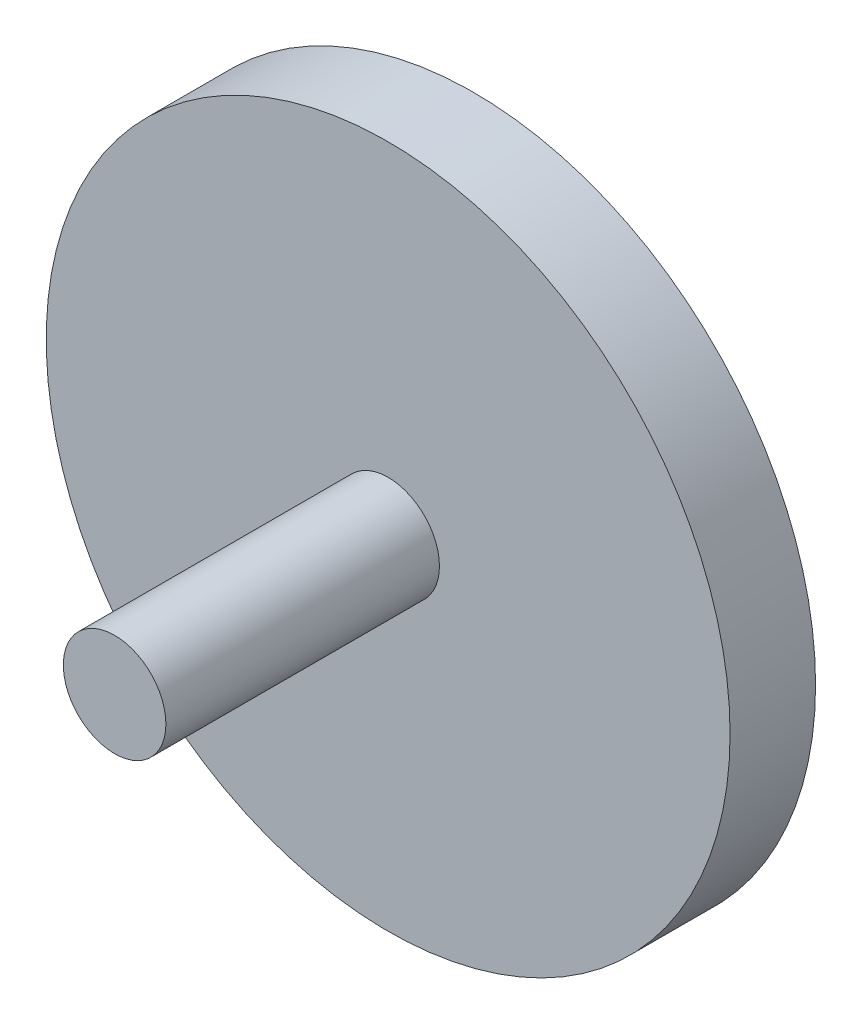
from build123d import *

# Parameters (mm, degrees)
SKETCH1_R           = 100
BOSS_EXTRUDE1_DEPTH = 25
SKETCH2_R           = 15
BOSS_EXTRUDE2_DEPTH = 80
SKETCH3_R           = 10
CUT_EXTRUDE1_DEPTH  = 5


with BuildPart() as part:
    # Sketch1 → Boss-Extrude1 (new body)
    with BuildSketch(Plane.XY):
        Circle(SKETCH1_R)
    extrude(amount=BOSS_EXTRUDE1_DEPTH)

    # Sketch2 → Boss-Extrude2 (add)
    with BuildSketch(Plane.XY.offset(25)):
        Circle(SKETCH2_R)
    extrude(amount=BOSS_EXTRUDE2_DEPTH)

    # Sketch3 → Cut-Extrude1 (cut)
    with BuildSketch(Plane(origin=(0, 0, 0), x_dir=(-1, 0, 0), z_dir=(0, 0, -1))):
        with Locations((0, 50)):
            Circle(SKETCH3_R)
    extrude(amount=-CUT_EXTRUDE1_DEPTH, mode=Mode.SUBTRACT)


solid = part.part
